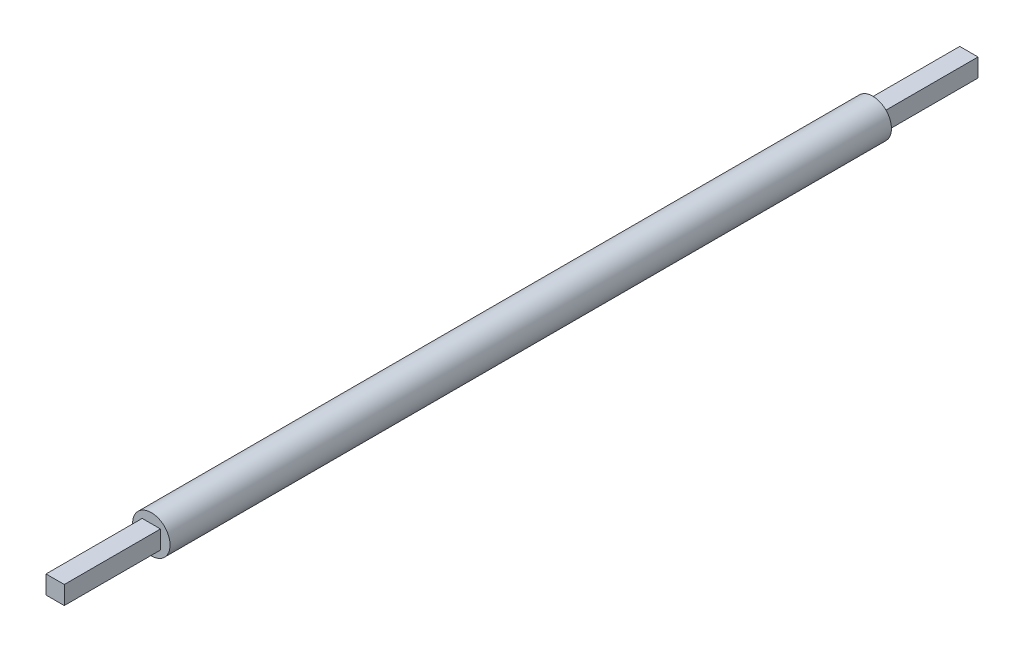
from build123d import *

# Parameters (mm, degrees)
SKETCH1_R           = 0.975
BOSS_EXTRUDE2_DEPTH = 18.75
SKETCH2_W           = 0.95
SKETCH2_H           = 0.95
BOSS_EXTRUDE3_DEPTH = 5


with BuildPart() as part:
    # Sketch1 → Boss-Extrude2 (new body)
    with BuildSketch(Plane.XY):
        Circle(SKETCH1_R)
    boss_extrude2 = extrude(amount=BOSS_EXTRUDE2_DEPTH)

    # Sketch2 → Boss-Extrude3 (add)
    with BuildSketch(Plane.XY.offset(18.75)):
        Rectangle(SKETCH2_W, SKETCH2_H)
    boss_extrude3 = extrude(amount=BOSS_EXTRUDE3_DEPTH)

    # Mirror1: Boss-Extrude2, Boss-Extrude3 across plane
    add(boss_extrude2.mirror(Plane.XY))
    add(boss_extrude3.mirror(Plane.XY))


solid = part.part
